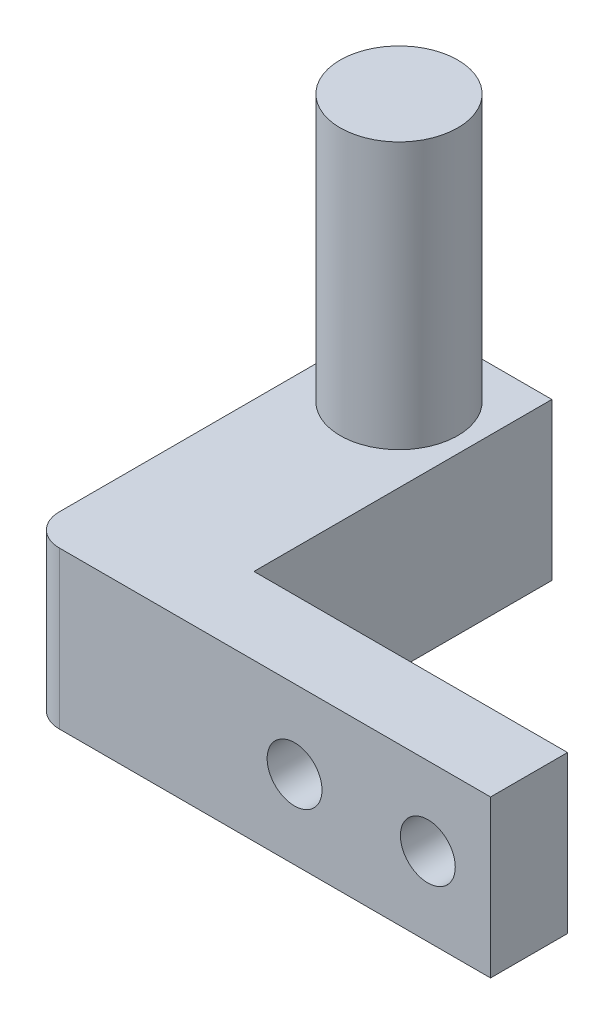
from build123d import *

# Parameters (mm, degrees)
SKETCH1_W           = 12.5
SKETCH1_H           = 10
BOSS_EXTRUDE1_DEPTH = 10
SKETCH2_W           = 10
SKETCH2_H           = 10
BOSS_EXTRUDE2_DEPTH = 5
SKETCH3_R           = 3.75
BOSS_EXTRUDE3_DEPTH = 17
SKETCH4_W           = 4
SKETCH4_H           = 10
CUT_EXTRUDE1_DEPTH  = 11
SKETCH5_W           = 9.5
SKETCH5_H           = 10
BOSS_EXTRUDE4_DEPTH = 12.5
SKETCH6_W           = 5
SKETCH6_H           = 10
BOSS_EXTRUDE5_DEPTH = 30
SKETCH7_R           = 1.75
CUT_EXTRUDE2_DEPTH  = 23.5
SKETCH8_W           = 30
SKETCH8_H           = 5
CUT_EXTRUDE4_DEPTH  = 10
SKETCH10_W          = 9.5
SKETCH10_H          = 10
CUT_EXTRUDE6_DEPTH  = 3.49
SKETCH11_W          = 9.5
SKETCH11_H          = 10
BOSS_EXTRUDE6_DEPTH = 3.9
SKETCH12_W          = 4
SKETCH12_H          = 10
BOSS_EXTRUDE7_DEPTH = 20
SKETCH13_W          = 20
SKETCH13_H          = 0.09
CUT_EXTRUDE7_DEPTH  = 28
SKETCH14_R          = 1.75
CUT_EXTRUDE8_DEPTH  = 23.91
SKETCH15_W          = 29.5
SKETCH15_H          = 10
SKETCH15_R          = 1.75
BOSS_EXTRUDE8_DEPTH = 1
FILLET1_R           = 2


with BuildPart() as part:
    # Sketch1 → Boss-Extrude1 (new body)
    with BuildSketch(Plane.XY):
        with Locations((6.25, 5)):
            Rectangle(SKETCH1_W, SKETCH1_H)
    extrude(amount=BOSS_EXTRUDE1_DEPTH)

    # Sketch2 → Boss-Extrude2 (add)
    with BuildSketch(Plane.ZY):
        with Locations((5, 5)):
            Rectangle(SKETCH2_W, SKETCH2_H)
    extrude(amount=BOSS_EXTRUDE2_DEPTH)

    # Sketch3 → Boss-Extrude3 (add)
    with BuildSketch(Plane(origin=(0, 10, 0), x_dir=(1, 0, 0), z_dir=(0, 1, 0))):
        with Locations((3.75, -5)):
            Circle(SKETCH3_R)
    extrude(amount=BOSS_EXTRUDE3_DEPTH)

    # Sketch4 → Cut-Extrude1 (cut, through all)
    with BuildSketch(Plane(origin=(0, 10, 0), x_dir=(1, 0, 0), z_dir=(0, 1, 0))):
        with Locations((10.5, -5)):
            Rectangle(SKETCH4_W, SKETCH4_H)
        with Locations((-3, -5)):
            Rectangle(SKETCH4_W, SKETCH4_H)
    extrude(amount=-CUT_EXTRUDE1_DEPTH, mode=Mode.SUBTRACT)

    # Sketch5 → Boss-Extrude4 (add)
    with BuildSketch(Plane.XY.offset(10)):
        with Locations((3.75, 5)):
            Rectangle(SKETCH5_W, SKETCH5_H)
    extrude(amount=BOSS_EXTRUDE4_DEPTH)

    # Sketch6 → Boss-Extrude5 (add)
    with BuildSketch(Plane(origin=(8.5, 0, 0), x_dir=(0, 0, -1), z_dir=(1, 0, 0))):
        with Locations((-20, 5)):
            Rectangle(SKETCH6_W, SKETCH6_H)
    extrude(amount=BOSS_EXTRUDE5_DEPTH)

    # Sketch7 → Cut-Extrude2 (cut, through all)
    with BuildSketch(Plane.XY.offset(22.5)):
        with Locations((22.5, 5)):
            Circle(SKETCH7_R)
        with Locations((33.5, 5)):
            Circle(SKETCH7_R)
    extrude(amount=-CUT_EXTRUDE2_DEPTH, mode=Mode.SUBTRACT)

    # Sketch8 → Cut-Extrude4 (cut)
    with BuildSketch(Plane(origin=(0, 10, 0), x_dir=(1, 0, 0), z_dir=(0, 1, 0))):
        with Locations((23.5, -20)):
            Rectangle(SKETCH8_W, SKETCH8_H)
    extrude(amount=-CUT_EXTRUDE4_DEPTH, mode=Mode.SUBTRACT)

    # Sketch10 → Cut-Extrude6 (cut)
    with BuildSketch(Plane.XY.offset(22.5)):
        with Locations((3.75, 5)):
            Rectangle(SKETCH10_W, SKETCH10_H)
    extrude(amount=-CUT_EXTRUDE6_DEPTH, mode=Mode.SUBTRACT)

    # Sketch11 → Boss-Extrude6 (add)
    with BuildSketch(Plane.XY.offset(19.01)):
        with Locations((3.75, 5)):
            Rectangle(SKETCH11_W, SKETCH11_H)
    extrude(amount=BOSS_EXTRUDE6_DEPTH)

    # Sketch12 → Boss-Extrude7 (add)
    with BuildSketch(Plane(origin=(8.5, 0, 0), x_dir=(0, 0, -1), z_dir=(1, 0, 0))):
        with Locations((-20.91, 5)):
            Rectangle(SKETCH12_W, SKETCH12_H)
    extrude(amount=BOSS_EXTRUDE7_DEPTH)

    # Sketch13 → Cut-Extrude7 (cut, through all)
    with BuildSketch(Plane(origin=(0, 0, 0), x_dir=(-1, 0, 0), z_dir=(0, -1, 0))):
        with Locations((-18.5, -18.955)):
            Rectangle(SKETCH13_W, SKETCH13_H)
    extrude(amount=-CUT_EXTRUDE7_DEPTH, mode=Mode.SUBTRACT)

    # Sketch14 → Cut-Extrude8 (cut, through all)
    with BuildSketch(Plane.XY.offset(22.91)):
        with Locations((16, 5)):
            Circle(SKETCH14_R)
        with Locations((24.5, 5)):
            Circle(SKETCH14_R)
    extrude(amount=-CUT_EXTRUDE8_DEPTH, mode=Mode.SUBTRACT)

    # Sketch15 → Boss-Extrude8 (add)
    with BuildSketch(Plane.XY.offset(22.91)):
        with Locations((13.75, 5)):
            Rectangle(SKETCH15_W, SKETCH15_H)
        with Locations((24.5, 5)):
            Circle(SKETCH15_R, mode=Mode.SUBTRACT)
        with Locations((16, 5)):
            Circle(SKETCH15_R, mode=Mode.SUBTRACT)
    extrude(amount=BOSS_EXTRUDE8_DEPTH)

    # Fillet1
    fillet1_edges = [part.edges().sort_by_distance(p)[0] for p in [
        (-1, 5, 23.91),
    ]]
    fillet(fillet1_edges, radius=FILLET1_R)


solid = part.part
